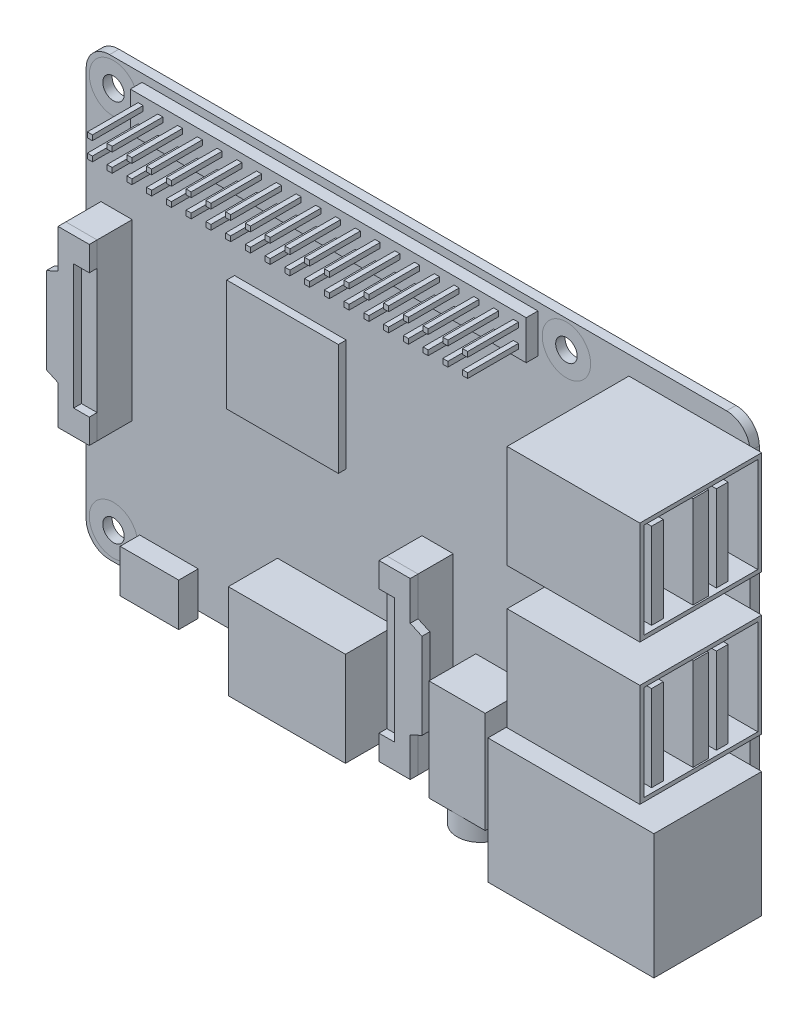
from build123d import *

# Parameters (mm, degrees)
SKIZZE1_W                          = 85
SKIZZE1_H                          = 56
AUFSATZ_LINEAR_AUSTRAGEN1_DEPTH    = 1.2
VERRUNDUNG1_R                      = 3
SKIZZE2_R                          = 1.375
SCHNITT_LINEAR_AUSTRAGEN1_DEPTH    = 5
AUFSATZ_LINEAR_START               = 5.5
AUFSATZ_LINEAR_AUSTRAGEN2_DEPTH    = 1
AUFSATZ_LINEAR_AUSTRAGEN2_2_DEPTH  = 1
AUFSATZ_LINEAR_AUSTRAGEN3_DEPTH    = 1
SKIZZE6_W                          = 4
SKIZZE6_H                          = 22.3
AUFSATZ_LINEAR_AUSTRAGEN4_DEPTH    = 4.5
AUFSATZ_LINEAR_AUSTRAGEN4_2_DEPTH  = 4.5
SKIZZE7_W                          = 50.7
SKIZZE7_H                          = 5
AUFSATZ_LINEAR_AUSTRAGEN5_DEPTH    = 1.5
SKIZZE8_W                          = 0.65
SKIZZE8_H                          = 0.65
AUFSATZ_LINEAR_AUSTRAGEN6_DEPTH    = 6.5
SKIZZE11_W                         = 11.5
SKIZZE11_H                         = 12
AUFSATZ_LINEAR_AUSTRAGEN7_DEPTH    = 2
SKIZZE12_W                         = 7.5
SKIZZE12_H                         = 5.5
AUFSATZ_LINEAR_AUSTRAGEN8_DEPTH    = 2.5
SKIZZE13_W                         = 15
SKIZZE13_H                         = 12.1
AUFSATZ_LINEAR_AUSTRAGEN9_DEPTH    = 6.3
SKIZZE14_W                         = 7.2
SKIZZE14_H                         = 13
AUFSATZ_LINEAR_AUSTRAGEN10_DEPTH   = 6
SKIZZE15_R                         = 3
AUFSATZ_LINEAR_AUSTRAGEN11_DEPTH   = 2.5
SKIZZE16_W                         = 21.25
SKIZZE16_H                         = 16
AUFSATZ_LINEAR_AUSTRAGEN12_DEPTH   = 13.8
SKIZZE17_W                         = 17
SKIZZE17_H                         = 13.2
AUFSATZ_LINEAR_AUSTRAGEN13_DEPTH   = 15.6
SCHALE1_T                          = -0.5
SKIZZE18_W                         = 2
SKIZZE18_H                         = 11.8
AUFSATZ_LINEAR_AUSTRAGEN14_DEPTH   = 16.5
SKIZZE19_W                         = 1.5
SKIZZE19_H                         = 11
AUFSATZ_LINEAR_AUSTRAGEN15_DEPTH   = 16.5
AUFSATZ_LINEAR_AUSTRAGEN15_2_DEPTH = 16.5
LINEARES_MUSTER1_COUNT             = 2
LINEARES_MUSTER1_PITCH             = 18
SKIZZE20_W                         = 14.3
SKIZZE20_H                         = 14.3
AUFSATZ_LINEAR_AUSTRAGEN16_DEPTH   = 1


with BuildPart() as part:
    # Skizze1 → Aufsatz-Linear austragen1 (new body)
    with BuildSketch(Plane.XY):
        Rectangle(SKIZZE1_W, SKIZZE1_H)
    extrude(amount=AUFSATZ_LINEAR_AUSTRAGEN1_DEPTH)

    # Verrundung1
    verrundung1_edges = [part.edges().sort_by_distance(p)[0] for p in [
        (-42.5, 28, 0.6),
        (42.5, 28, 0.6),
        (42.5, -28, 0.6),
        (-42.5, -28, 0.6),
    ]]
    fillet(verrundung1_edges, radius=VERRUNDUNG1_R)

    # Skizze2 → Schnitt-Linear austragen1 (cut)
    with BuildSketch(Plane.XY.offset(1.2)):
        with Locations((-39, 24.5)):
            Circle(SKIZZE2_R)
        with Locations((-39, -24.5)):
            Circle(SKIZZE2_R)
        with Locations((19, 24.5)):
            Circle(SKIZZE2_R)
        with Locations((19, -24.5)):
            Circle(SKIZZE2_R)
    extrude(amount=-SCHNITT_LINEAR_AUSTRAGEN1_DEPTH, mode=Mode.SUBTRACT)


with BuildPart() as body_2:
    # Skizze4 → Aufsatz-Linear austragen2 (new body)
    with BuildSketch(Plane.XY.offset(1.2).offset(AUFSATZ_LINEAR_START)):
        Polygon((-36.6, 11.15), (-40.6, 11.15), (-40.6, -11.15), (-36.6, -11.15), (-36.6, -8), (-38.6, -8), (-38.6, 8), (-36.6, 8), align=None)
    extrude(amount=-AUFSATZ_LINEAR_AUSTRAGEN2_DEPTH)



with BuildPart() as body_3:
    # Skizze4 → Aufsatz-Linear austragen2 2 (new body)
    with BuildSketch(Plane.XY.offset(1.2).offset(AUFSATZ_LINEAR_START)):
        Polygon((4.5, -5.35), (0.5, -5.35), (0.5, -8.5), (2.5, -8.5), (2.5, -24.5), (0.5, -24.5), (0.5, -27.65), (4.5, -27.65), align=None)
    extrude(amount=-AUFSATZ_LINEAR_AUSTRAGEN2_2_DEPTH)


with BuildPart() as body_2_1:
    add(body_2.part)

    add(body_3.part)  # Aufsatz-Linear austragen3 merges body 3
    # Skizze5 → Aufsatz-Linear austragen3 (add)
    with BuildSketch(Plane.XY.offset(6.7)):
        Polygon((-40.6, -6.181818182), (-40.6, 6.181818182), (-42.1, 5.5), (-42.1, -5.5), align=None)
        Polygon((6, -11), (4.5, -10.318181818), (4.5, -22.681818182), (6, -22), align=None)
    extrude(amount=-AUFSATZ_LINEAR_AUSTRAGEN3_DEPTH)


with BuildPart() as body_3_2:
    # Skizze6 → Aufsatz-Linear austragen4 (new body)
    with BuildSketch(Plane.XY.offset(1.2)):
        with Locations((-38.6, 0)):
            Rectangle(SKIZZE6_W, SKIZZE6_H)
    extrude(amount=AUFSATZ_LINEAR_AUSTRAGEN4_DEPTH)


with BuildPart() as body_4:
    # Skizze6 → Aufsatz-Linear austragen4 2 (new body)
    with BuildSketch(Plane.XY.offset(1.2)):
        with Locations((2.5, -16.5)):
            Rectangle(SKIZZE6_W, SKIZZE6_H)
    extrude(amount=AUFSATZ_LINEAR_AUSTRAGEN4_2_DEPTH)


with BuildPart() as body_5:
    # Skizze7 → Aufsatz-Linear austragen5 (new body)
    with BuildSketch(Plane.XY.offset(1.2)):
        with Locations((-10, 24.5)):
            Rectangle(SKIZZE7_W, SKIZZE7_H)
    extrude(amount=AUFSATZ_LINEAR_AUSTRAGEN5_DEPTH)

    # Skizze8 → Aufsatz-Linear austragen6 (add)
    with BuildSketch(Plane.XY.offset(2.7)):
        with Locations((-34.025, 25.675)):
            Rectangle(SKIZZE8_W, SKIZZE8_H)
        with Locations((-31.496052632, 25.675)):
            Rectangle(SKIZZE8_W, SKIZZE8_H)
        with Locations((-28.967105263, 25.675)):
            Rectangle(SKIZZE8_W, SKIZZE8_H)
        with Locations((-26.438157895, 25.675)):
            Rectangle(SKIZZE8_W, SKIZZE8_H)
        with Locations((-23.909210526, 25.675)):
            Rectangle(SKIZZE8_W, SKIZZE8_H)
        with Locations((-21.380263158, 25.675)):
            Rectangle(SKIZZE8_W, SKIZZE8_H)
        with Locations((-18.851315789, 25.675)):
            Rectangle(SKIZZE8_W, SKIZZE8_H)
        with Locations((-16.322368421, 25.675)):
            Rectangle(SKIZZE8_W, SKIZZE8_H)
        with Locations((-13.793421053, 25.675)):
            Rectangle(SKIZZE8_W, SKIZZE8_H)
        with Locations((-11.264473684, 25.675)):
            Rectangle(SKIZZE8_W, SKIZZE8_H)
        with Locations((-8.735526316, 25.675)):
            Rectangle(SKIZZE8_W, SKIZZE8_H)
        with Locations((-6.206578947, 25.675)):
            Rectangle(SKIZZE8_W, SKIZZE8_H)
        with Locations((-3.677631579, 25.675)):
            Rectangle(SKIZZE8_W, SKIZZE8_H)
        with Locations((-1.148684211, 25.675)):
            Rectangle(SKIZZE8_W, SKIZZE8_H)
        with Locations((1.380263158, 25.675)):
            Rectangle(SKIZZE8_W, SKIZZE8_H)
        with Locations((3.909210526, 25.675)):
            Rectangle(SKIZZE8_W, SKIZZE8_H)
        with Locations((6.438157895, 25.675)):
            Rectangle(SKIZZE8_W, SKIZZE8_H)
        with Locations((8.967105263, 25.675)):
            Rectangle(SKIZZE8_W, SKIZZE8_H)
        with Locations((11.496052632, 25.675)):
            Rectangle(SKIZZE8_W, SKIZZE8_H)
        with Locations((14.025, 25.675)):
            Rectangle(SKIZZE8_W, SKIZZE8_H)
        with Locations((14.025, 23.325)):
            Rectangle(SKIZZE8_W, SKIZZE8_H)
        with Locations((11.496052632, 23.325)):
            Rectangle(SKIZZE8_W, SKIZZE8_H)
        with Locations((8.967105263, 23.325)):
            Rectangle(SKIZZE8_W, SKIZZE8_H)
        with Locations((6.438157895, 23.325)):
            Rectangle(SKIZZE8_W, SKIZZE8_H)
        with Locations((3.909210526, 23.325)):
            Rectangle(SKIZZE8_W, SKIZZE8_H)
        with Locations((1.380263158, 23.325)):
            Rectangle(SKIZZE8_W, SKIZZE8_H)
        with Locations((-1.148684211, 23.325)):
            Rectangle(SKIZZE8_W, SKIZZE8_H)
        with Locations((-3.677631579, 23.325)):
            Rectangle(SKIZZE8_W, SKIZZE8_H)
        with Locations((-6.206578947, 23.325)):
            Rectangle(SKIZZE8_W, SKIZZE8_H)
        with Locations((-8.735526316, 23.325)):
            Rectangle(SKIZZE8_W, SKIZZE8_H)
        with Locations((-11.264473684, 23.325)):
            Rectangle(SKIZZE8_W, SKIZZE8_H)
        with Locations((-13.793421053, 23.325)):
            Rectangle(SKIZZE8_W, SKIZZE8_H)
        with Locations((-16.322368421, 23.325)):
            Rectangle(SKIZZE8_W, SKIZZE8_H)
        with Locations((-18.851315789, 23.325)):
            Rectangle(SKIZZE8_W, SKIZZE8_H)
        with Locations((-21.380263158, 23.325)):
            Rectangle(SKIZZE8_W, SKIZZE8_H)
        with Locations((-23.909210526, 23.325)):
            Rectangle(SKIZZE8_W, SKIZZE8_H)
        with Locations((-26.438157895, 23.325)):
            Rectangle(SKIZZE8_W, SKIZZE8_H)
        with Locations((-28.967105263, 23.325)):
            Rectangle(SKIZZE8_W, SKIZZE8_H)
        with Locations((-31.496052632, 23.325)):
            Rectangle(SKIZZE8_W, SKIZZE8_H)
        with Locations((-34.025, 23.325)):
            Rectangle(SKIZZE8_W, SKIZZE8_H)
    extrude(amount=AUFSATZ_LINEAR_AUSTRAGEN6_DEPTH)


with BuildPart() as body_6:
    # Skizze11 → Aufsatz-Linear austragen7 (new body)
    with BuildSketch(Plane(origin=(0, 0, 0), x_dir=(-1, 0, 0), z_dir=(0, 0, -1))):
        with Locations((35.75, 0)):
            Rectangle(SKIZZE11_W, SKIZZE11_H)
    extrude(amount=AUFSATZ_LINEAR_AUSTRAGEN7_DEPTH)


with BuildPart() as body_7:
    # Skizze12 → Aufsatz-Linear austragen8 (new body)
    with BuildSketch(Plane.XY.offset(1.2)):
        with Locations((-31.9, -26.1)):
            Rectangle(SKIZZE12_W, SKIZZE12_H)
    extrude(amount=AUFSATZ_LINEAR_AUSTRAGEN8_DEPTH)


with BuildPart() as body_8:
    # Skizze13 → Aufsatz-Linear austragen9 (new body)
    with BuildSketch(Plane.XY.offset(1.2)):
        with Locations((-10.5, -23.15)):
            Rectangle(SKIZZE13_W, SKIZZE13_H)
    extrude(amount=AUFSATZ_LINEAR_AUSTRAGEN9_DEPTH)


with BuildPart() as body_9:
    # Skizze14 → Aufsatz-Linear austragen10 (new body)
    with BuildSketch(Plane.XY.offset(1.2)):
        with Locations((11, -21.5)):
            Rectangle(SKIZZE14_W, SKIZZE14_H)
    extrude(amount=AUFSATZ_LINEAR_AUSTRAGEN10_DEPTH)

    # Skizze15 → Aufsatz-Linear austragen11 (add)
    with BuildSketch(Plane.XZ.offset(28)):
        with Locations(Location((11, 4.2, 0), (0, 0, 270))):
            Circle(SKIZZE15_R)
    extrude(amount=AUFSATZ_LINEAR_AUSTRAGEN11_DEPTH)


with BuildPart() as body_10:
    # Skizze16 → Aufsatz-Linear austragen12 (new body)
    with BuildSketch(Plane.XY.offset(1.2)):
        with Locations((33.375, -17.75)):
            Rectangle(SKIZZE16_W, SKIZZE16_H)
    extrude(amount=AUFSATZ_LINEAR_AUSTRAGEN12_DEPTH)


with BuildPart() as body_11:
    # Skizze17 → Aufsatz-Linear austragen13 (new body)
    with BuildSketch(Plane.XY.offset(1.2)):
        with Locations((35.5, 1)):
            Rectangle(SKIZZE17_W, SKIZZE17_H)
    extrude(amount=AUFSATZ_LINEAR_AUSTRAGEN13_DEPTH)

    # Schale1
    schale1_openings = [body_11.faces().sort_by_distance(p)[0] for p in [
        (44, 1, 9),
    ]]
    offset(amount=SCHALE1_T, openings=schale1_openings, kind=Kind.INTERSECTION)

    # Skizze18 → Aufsatz-Linear austragen14 (add)
    with BuildSketch(Plane(origin=(44, 0, 0), x_dir=(0, 0, -1), z_dir=(1, 0, 0))):
        with Locations((-9, 1)):
            Rectangle(SKIZZE18_W, SKIZZE18_H)
    extrude(amount=-AUFSATZ_LINEAR_AUSTRAGEN14_DEPTH)


with BuildPart() as body_12:
    # Skizze19 → Aufsatz-Linear austragen15 (new body)
    with BuildSketch(Plane(origin=(27.5, 0, 0), x_dir=(0, 0, -1), z_dir=(1, 0, 0))):
        with Locations((-14.55, 1)):
            Rectangle(SKIZZE19_W, SKIZZE19_H)
    extrude(amount=AUFSATZ_LINEAR_AUSTRAGEN15_DEPTH)


with BuildPart() as body_13:
    # Skizze19 → Aufsatz-Linear austragen15 2 (new body)
    with BuildSketch(Plane(origin=(27.5, 0, 0), x_dir=(0, 0, -1), z_dir=(1, 0, 0))):
        with Locations((-6.25, 1)):
            Rectangle(SKIZZE19_W, SKIZZE19_H)
    extrude(amount=AUFSATZ_LINEAR_AUSTRAGEN15_2_DEPTH)


with BuildPart() as lineares_muster1_1:
    # Lineares Muster1: pattern copy
    add(body_12.part.moved(Location(Vector(0, 1, 0) * (1 * LINEARES_MUSTER1_PITCH))))


with BuildPart() as lineares_muster1_2:
    # Lineares Muster1: pattern copy
    add(body_13.part.moved(Location(Vector(0, 1, 0) * (1 * LINEARES_MUSTER1_PITCH))))


with BuildPart() as lineares_muster1_3:
    # Lineares Muster1: pattern copy
    add(body_11.part.moved(Location(Vector(0, 1, 0) * (1 * LINEARES_MUSTER1_PITCH))))


with BuildPart() as body_17:
    # Skizze20 → Aufsatz-Linear austragen16 (new body)
    with BuildSketch(Plane.XY.offset(1.2)):
        with Locations((-16.35, 4.35)):
            Rectangle(SKIZZE20_W, SKIZZE20_H)
    extrude(amount=AUFSATZ_LINEAR_AUSTRAGEN16_DEPTH)


solid = Compound([part.part, body_2_1.part, body_3_2.part, body_4.part, body_5.part, body_6.part, body_7.part, body_8.part, body_9.part, body_10.part, body_11.part, body_12.part, body_13.part, lineares_muster1_1.part, lineares_muster1_2.part, lineares_muster1_3.part, body_17.part])
